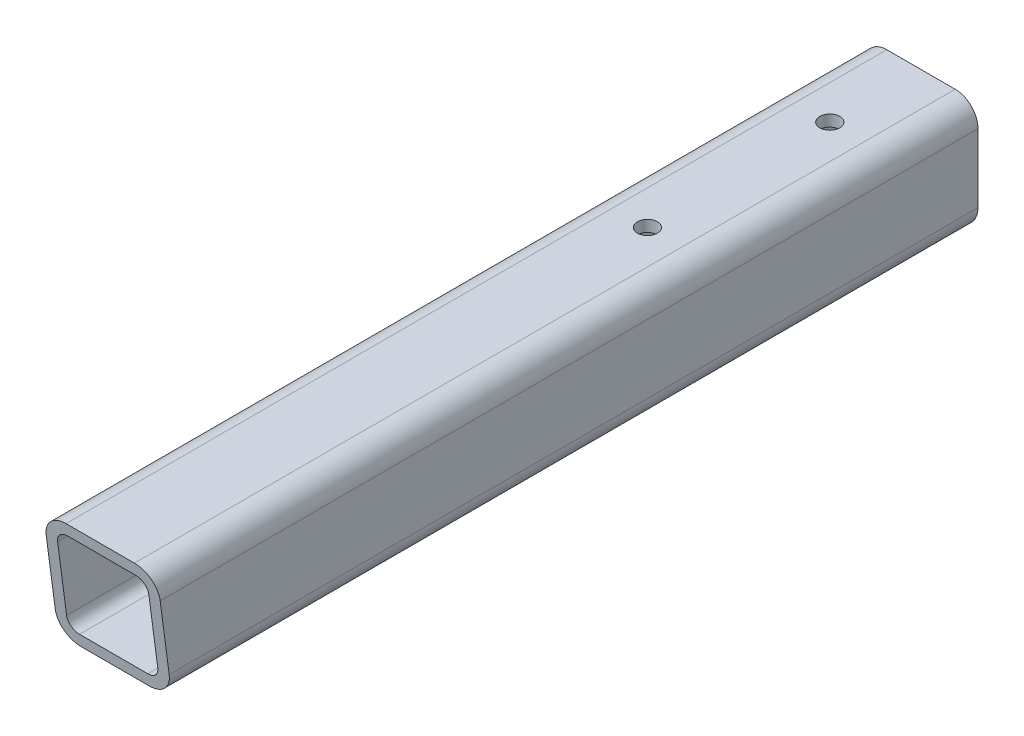
from build123d import *

# Parameters (mm, degrees)
BOSS_EXTRUDE1_DEPTH = 228.6
SKETCH3_R           = 5.55625
CUT_EXTRUDE1_DEPTH  = 64.5
CUT_EXTRUDE2_DEPTH  = 64.5


with BuildPart() as part:
    # Sketch1 → Boss-Extrude1 (new body, symmetric)
    with BuildSketch(Plane.XY):
        with BuildLine():
            Line((19.05, 31.75), (-19.05, 31.75))
            ThreePointArc((-19.05, 31.75), (-28.030256121, 28.030256121), (-31.75, 19.05))
            Line((-31.75, 19.05), (-31.75, -19.05))
            ThreePointArc((-31.75, -19.05), (-28.030256121, -28.030256121), (-19.05, -31.75))
            Line((-19.05, -31.75), (19.05, -31.75))
            ThreePointArc((19.05, -31.75), (28.030256121, -28.030256121), (31.75, -19.05))
            Line((31.75, -19.05), (31.75, 19.05))
            ThreePointArc((31.75, 19.05), (28.030256121, 28.030256121), (19.05, 31.75))
        make_face()
        with BuildLine():
            ThreePointArc((-25.4, -19.05), (-23.540128061, -23.540128061), (-19.05, -25.4))
            Line((-19.05, -25.4), (19.05, -25.4))
            ThreePointArc((19.05, -25.4), (23.540128061, -23.540128061), (25.4, -19.05))
            Line((25.4, -19.05), (25.4, 19.05))
            ThreePointArc((25.4, 19.05), (23.540128061, 23.540128061), (19.05, 25.4))
            Line((19.05, 25.4), (-19.05, 25.4))
            ThreePointArc((-19.05, 25.4), (-23.540128061, 23.540128061), (-25.4, 19.05))
            Line((-25.4, 19.05), (-25.4, -19.05))
        make_face(mode=Mode.SUBTRACT)
    extrude(amount=BOSS_EXTRUDE1_DEPTH, both=True)

    # Sketch3 → Cut-Extrude1 (cut, through all)
    with BuildSketch(Plane(origin=(0, 31.75, 0), x_dir=(1, 0, 0), z_dir=(0, 1, 0))):
        with Locations((0, 177.8)):
            Circle(SKETCH3_R)
        with Locations((0, 76.2)):
            Circle(SKETCH3_R)
    extrude(amount=-CUT_EXTRUDE1_DEPTH, mode=Mode.SUBTRACT)

    # Sketch4 → Cut-Extrude2 (cut, through all)
    with BuildSketch(Plane(origin=(31.75, 0, 0), x_dir=(0, 0, -1), z_dir=(1, 0, 0))):
        Polygon((-221.912053123, -19.05), (-228.6, -19.05), (-228.6, -114.266943845), (-209.376504653, -114.266943845), align=None)
        Polygon((-226.928013281, 19.05), (-228.6, 19.05), (-228.6, -19.05), (-221.912053123, -19.05), align=None)
        Polygon((-226.928013281, 19.05), (-228.6, 31.75), (-228.6, 19.05), align=None)
    extrude(amount=-CUT_EXTRUDE2_DEPTH, mode=Mode.SUBTRACT)


solid = part.part
